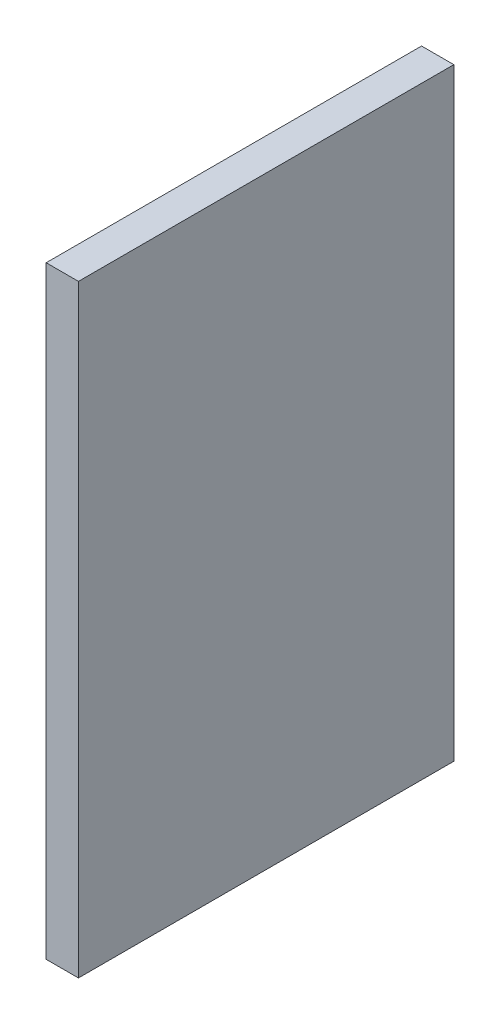
from build123d import *

# Parameters (mm, degrees)
SKETCH_1_W      = 28
SKETCH_1_H      = 45
EXTRUDE_1_DEPTH = 2.408


with BuildPart() as part:
    # Эскиз1 → Вытянуть1 (new body)
    with BuildSketch(Plane(origin=(0, 0, 0), x_dir=(0, 0, -1), z_dir=(1, 0, 0))):
        with Locations((14, 22.5)):
            Rectangle(SKETCH_1_W, SKETCH_1_H)
    extrude(amount=EXTRUDE_1_DEPTH)


solid = part.part
